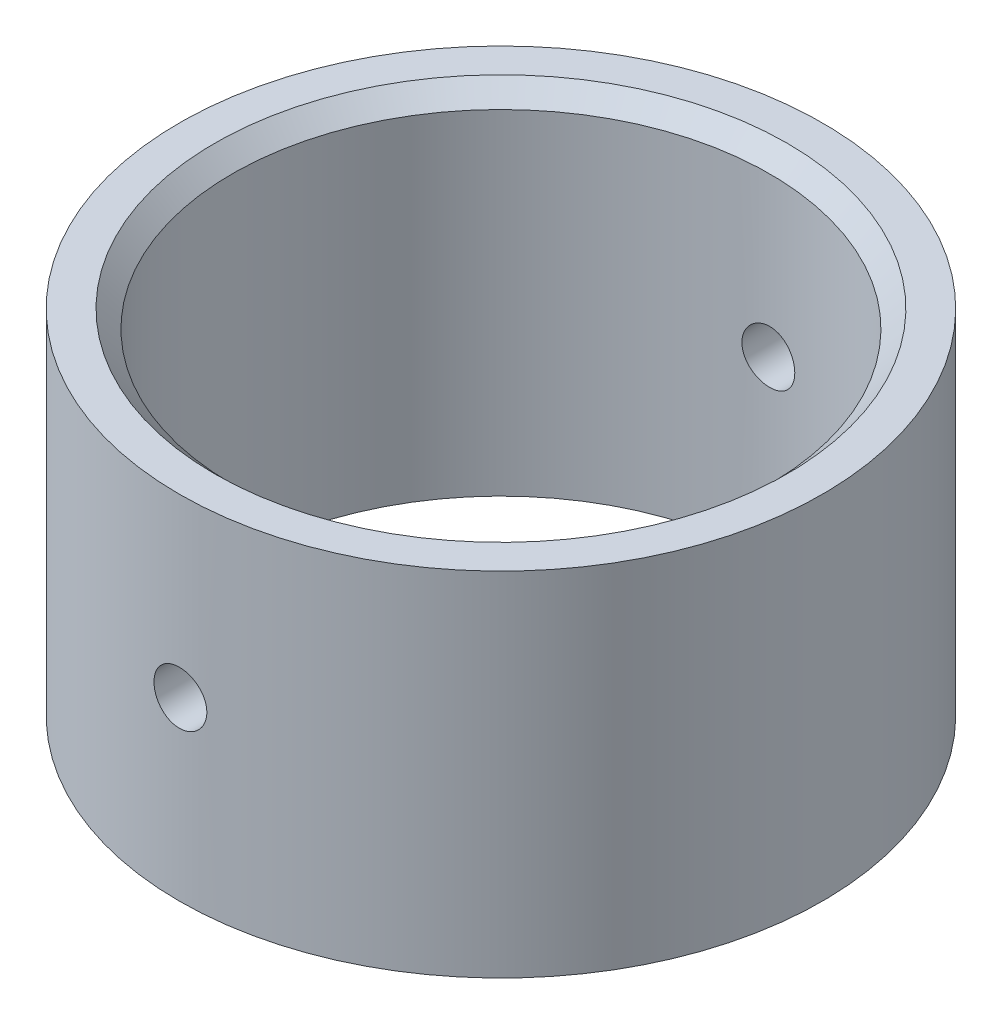
from build123d import *

# Parameters (mm, degrees)
SKETCH1_R               = 18.25
SKETCH1_R_2             = 15.25
BOSS_EXTRUDE1_DEPTH     = 20
SKETCH2_R               = 1.5
CUT_EXTRUDE1_DEPTH      = 19.25
CUT_EXTRUDE1_DEPTH_BACK = 19.25
CHAMFER1_SIZE           = 1


with BuildPart() as part:
    # Sketch1 → Boss-Extrude1 (new body)
    with BuildSketch(Plane(origin=(0, 0, 0), x_dir=(1, 0, 0), z_dir=(0, 1, 0))):
        Circle(SKETCH1_R)
        Circle(SKETCH1_R_2, mode=Mode.SUBTRACT)
    extrude(amount=BOSS_EXTRUDE1_DEPTH)

    # Sketch2 → Cut-Extrude1 (cut, two sides)
    with BuildSketch(Plane.XY) as cut_extrude1_sk:
        with Locations((0, 10)):
            Circle(SKETCH2_R)
    extrude(amount=CUT_EXTRUDE1_DEPTH, mode=Mode.SUBTRACT)
    extrude(cut_extrude1_sk.sketch, amount=-CUT_EXTRUDE1_DEPTH_BACK, mode=Mode.SUBTRACT)

    # Chamfer1
    chamfer1_edges = [part.edges().sort_by_distance(p)[0] for p in [
        (-15.25, 20, 0),
    ]]
    chamfer(chamfer1_edges, length=CHAMFER1_SIZE)


solid = part.part
